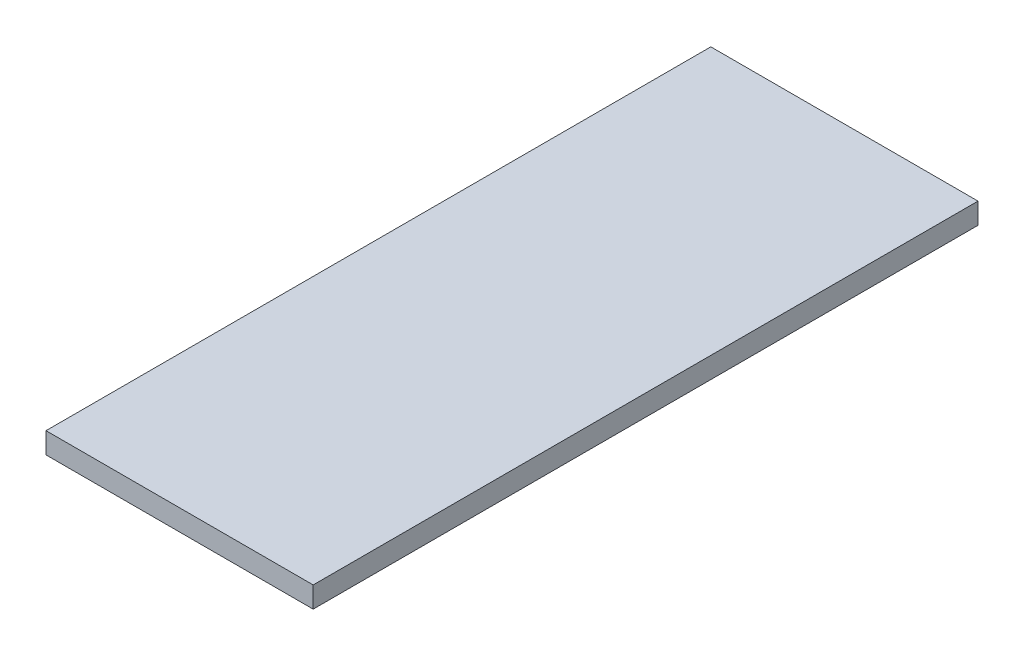
from build123d import *

# Parameters (mm, degrees)
SKETCH1_W           = 1400
SKETCH1_H           = 110
BOSS_EXTRUDE1_DEPTH = 3483.5


with BuildPart() as part:
    # Sketch1 → Boss-Extrude1 (new body)
    with BuildSketch(Plane.XY):
        Rectangle(SKETCH1_W, SKETCH1_H)
    extrude(amount=BOSS_EXTRUDE1_DEPTH)


solid = part.part
